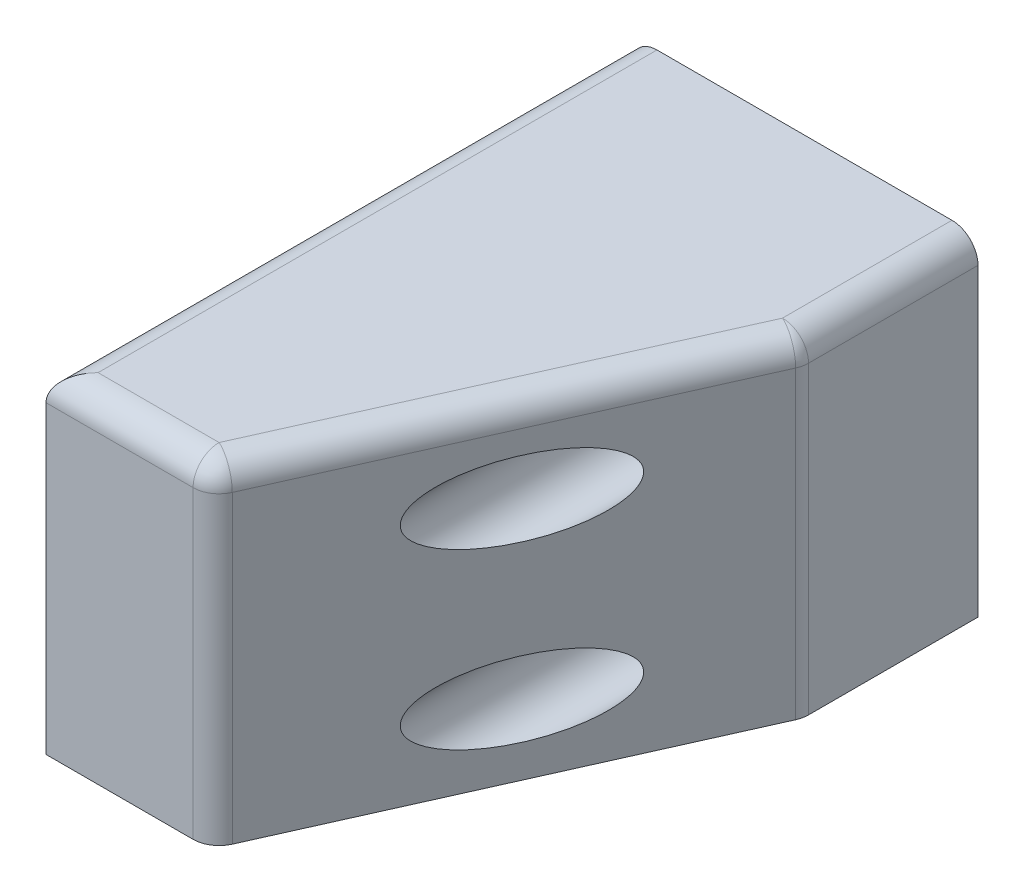
from build123d import *

# Parameters (mm, degrees)
SKETCH1_W               = 48.4
SKETCH1_H               = 50.8
BOSS_EXTRUDE1_DEPTH     = 85.62
CUT_EXTRUDE1_DEPTH      = 49.4
CUT_EXTRUDE2_DEPTH      = 70
SKETCH5_R               = 5.5
CUT_EXTRUDE3_DEPTH      = 80
SKETCH6_R               = 3.25
CUT_EXTRUDE4_DEPTH      = 6.62
CUT_EXTRUDE5_DEPTH      = 3
CUT_EXTRUDE5_DEPTH_BACK = 3
CUT_EXTRUDE6_REACH      = 35.4
SKETCH8_W               = 6
SKETCH8_H               = 10
CUT_EXTRUDE7_REACH      = 52.8
SKETCH4_R               = 3.25
FILLET1_R               = 3.81


with BuildPart() as part:
    # Sketch1 → Boss-Extrude1 (new body)
    with BuildSketch(Plane(origin=(0, 0, 0), x_dir=(0, 1, 0), z_dir=(0, 0, 1))):
        with Locations((24.2, 25.4)):
            Rectangle(SKETCH1_W, SKETCH1_H)
    extrude(amount=BOSS_EXTRUDE1_DEPTH)

    # Sketch2 → Cut-Extrude1 (cut, through all)
    with BuildSketch(Plane(origin=(0, 48.4, 0), x_dir=(-1, 0, 0), z_dir=(0, 1, 0))):
        Polygon((26.8, 85.62), (0, 25.62), (0, 85.62), align=None)
    extrude(amount=-CUT_EXTRUDE1_DEPTH, mode=Mode.SUBTRACT)

    # Sketch3 → Cut-Extrude2 (cut)
    with BuildSketch(Plane(origin=(0, 0, 0), x_dir=(1, 0, 0), z_dir=(0, 0, -1))):
        Polygon((-43.8, 0), (-43.8, -3), (-46.8, -3), (-46.8, -15), (-30.8, -15), (-30.8, -3), (-33.8, -3), (-33.8, 0), align=None)
    extrude(amount=-CUT_EXTRUDE2_DEPTH, mode=Mode.SUBTRACT)

    # Sketch5 → Cut-Extrude3 (cut)
    with BuildSketch(Plane.XY.offset(85.62)):
        with Locations((-12.7, 10.3)):
            Circle(SKETCH5_R)
        with Locations((-12.7, 35.7)):
            Circle(SKETCH5_R)
    extrude(amount=-CUT_EXTRUDE3_DEPTH, mode=Mode.SUBTRACT)

    # Sketch6 → Cut-Extrude4 (cut, through all)
    with BuildSketch(Plane.XY.offset(5.62)):
        with Locations((-12.7, 35.7)):
            Circle(SKETCH6_R)
        with Locations((-12.7, 10.3)):
            Circle(SKETCH6_R)
    extrude(amount=-CUT_EXTRUDE4_DEPTH, mode=Mode.SUBTRACT)

    # Sketch7 → Cut-Extrude5 (cut, two sides)
    with BuildSketch(Plane.ZY.offset(38.8)) as cut_extrude5_sk:
        Polygon((35.6, 43.773502692), (30.6, 40.886751346), (30.6, 35.113248654), (35.6, 32.226497308), (40.6, 35.113248654), (40.6, 40.886751346), align=None)
    extrude(amount=CUT_EXTRUDE5_DEPTH, mode=Mode.SUBTRACT)
    extrude(cut_extrude5_sk.sketch, amount=-CUT_EXTRUDE5_DEPTH_BACK, mode=Mode.SUBTRACT)

    # Sketch8 → Cut-Extrude6 (cut, up to next)
    with BuildSketch(Plane.XZ.offset(-15), mode=Mode.PRIVATE) as cut_extrude6_sk1:
        with Locations((-38.8, 35.6)):
            Rectangle(SKETCH8_W, SKETCH8_H)
    cut_extrude6_tool1 = extrude(cut_extrude6_sk1.sketch, amount=-CUT_EXTRUDE6_REACH, mode=Mode.PRIVATE) & part.part
    add(cut_extrude6_tool1.solids().sort_by_distance((-38.8, 15, 35.6))[0], mode=Mode.SUBTRACT)

    # Sketch4 → Cut-Extrude7 (cut, up to next)
    with BuildSketch(Plane(origin=(-50.8, 0, 0), x_dir=(0, -1, 0), z_dir=(-1, 0, 0)), mode=Mode.PRIVATE) as cut_extrude7_sk1:
        with Locations((-38, 35.6)):
            Circle(SKETCH4_R)
    cut_extrude7_tool1 = extrude(cut_extrude7_sk1.sketch, amount=-CUT_EXTRUDE7_REACH, mode=Mode.PRIVATE) & part.part
    add(cut_extrude7_tool1.solids().sort_by_distance((-50.8, 38, 35.6))[0], mode=Mode.SUBTRACT)

    # Fillet1
    fillet1_edges = [part.edges().sort_by_distance(p)[0] for p in [
        (-38.8, 48.4, 85.62),
        (0, 48.4, 12.81),
        (-26.8, 24.2, 85.62),
        (0, 24.2, 25.62),
        (-13.4, 48.4, 55.62),
        (-50.8, 48.4, 42.81),
    ]]
    fillet(fillet1_edges, radius=FILLET1_R)


solid = part.part
